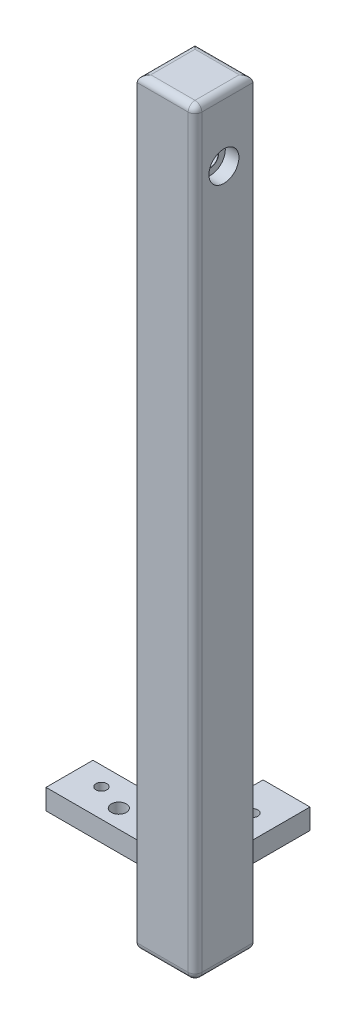
from build123d import *

# Parameters (mm, degrees)
SKETCH1_W                      = 8.5
SKETCH1_H                      = 111.5
BOSS_EXTRUDE5_DEPTH            = 8.5
M5X0_8_TAPPED_HOLE2_D          = 4.2
M5X0_8_TAPPED_HOLE2_DEPTH      = 20
M5X0_8_TAPPED_HOLE2_TIP        = 1.2618073
SKETCH35_W                     = 8.5
SKETCH35_H                     = 3
BOSS_EXTRUDE6_DEPTH            = 15
F_2_2_2_2_DIAMETER_HOLE1_D     = 2.2
F_2_2_2_2_DIAMETER_HOLE1_DEPTH = 13
M2X0_4_TAPPED_HOLE5_D          = 1.6
M2X0_4_TAPPED_HOLE5_DEPTH      = 3
SKETCH40_W                     = 8.5
SKETCH40_H                     = 3
BOSS_EXTRUDE7_DEPTH            = 10
M2X0_4_TAPPED_HOLE4_D          = 1.6
M2X0_4_TAPPED_HOLE4_DEPTH      = 3
FILLET1_R                      = 1
M2X0_4_TAPPED_HOLE3_D          = 2
M2X0_4_TAPPED_HOLE3_DEPTH      = 5.2
M2X0_4_TAPPED_HOLE3_TIP        = 0.600860619
SKETCH49_W                     = 1.6
SKETCH49_H                     = 10
SKETCH49_W_2                   = 15
SKETCH49_H_2                   = 1.6
CUT_EXTRUDE1_DEPTH             = 10


with BuildPart() as part:
    # Sketch1 → Boss-Extrude5 (new body)
    with BuildSketch(Plane.XY):
        with Locations((4.25, -55.75)):
            Rectangle(SKETCH1_W, SKETCH1_H)
    extrude(amount=BOSS_EXTRUDE5_DEPTH)

    # M5x0.8 Tapped Hole2
    with Locations(Plane(origin=(0, -111.5, 0), x_dir=(-1, 0, 0), z_dir=(0, -1, 0))):
        with Locations((-4.25, -4.25)):
            Hole(M5X0_8_TAPPED_HOLE2_D / 2, depth=M5X0_8_TAPPED_HOLE2_DEPTH)
            with Locations((0, 0, -(M5X0_8_TAPPED_HOLE2_DEPTH + M5X0_8_TAPPED_HOLE2_TIP / 2))):  # 118° drill point
                Cone(0, M5X0_8_TAPPED_HOLE2_D / 2, M5X0_8_TAPPED_HOLE2_TIP, mode=Mode.SUBTRACT)

    # Sketch35 → Boss-Extrude6 (add)
    with BuildSketch(Plane.ZY):
        with Locations((4.25, -100.5)):
            Rectangle(SKETCH35_W, SKETCH35_H)
    extrude(amount=BOSS_EXTRUDE6_DEPTH)

    # Ø2.2 (2.2) Diameter Hole1
    with Locations(Plane(origin=(0, -99, 0), x_dir=(1, 0, 0), z_dir=(0, 1, 0))):
        with Locations((-7, -4.2)):
            Hole(F_2_2_2_2_DIAMETER_HOLE1_D / 2, depth=F_2_2_2_2_DIAMETER_HOLE1_DEPTH)

    # M2x0.4 Tapped Hole5
    with Locations(Plane(origin=(0, -99, 0), x_dir=(1, 0, 0), z_dir=(0, 1, 0))):
        with Locations((-11, -2.75)):
            Hole(M2X0_4_TAPPED_HOLE5_D / 2, depth=M2X0_4_TAPPED_HOLE5_DEPTH)

    # Sketch40 → Boss-Extrude7 (add)
    with BuildSketch(Plane(origin=(0, 0, 0), x_dir=(-1, 0, 0), z_dir=(0, 0, -1))):
        with Locations((-4.25, -100.5)):
            Rectangle(SKETCH40_W, SKETCH40_H)
    extrude(amount=BOSS_EXTRUDE7_DEPTH)

    # M2x0.4 Tapped Hole4
    with Locations(Plane(origin=(0, -99, 0), x_dir=(1, 0, 0), z_dir=(0, 1, 0))):
        with Locations((3.45, 5)):
            Hole(M2X0_4_TAPPED_HOLE4_D / 2, depth=M2X0_4_TAPPED_HOLE4_DEPTH)

    # Sketch45 → CBORE for M2 Socket Head Cap Screw1 (revolve, cut)
    with BuildSketch(Plane(origin=(8.5, -9.5, 4.25), x_dir=(0, 0, -1), z_dir=(0, 1, 0))):
        Polygon((0, 0), (0, 23.500025), (1.2, 23.500025), (1.2, 2.025), (1.225, 2), (2.2, 2), (2.2, 0), align=None)
    revolve(axis=Axis((14.85, -9.5, 4.25), (-1, 0, 0)), mode=Mode.SUBTRACT)

    # Fillet1
    fillet1_edges = [part.edges().sort_by_distance(p)[0] for p in [
        (4.25, 0, 8.5),
        (2.15, -111.5, 4.25),
        (8.5, -55.75, 8.5),
        (4.25, 0, 0),
        (4.25, -111.5, 0),
        (4.25, -111.5, 8.5),
        (8.5, 0, 4.25),
        (0, 0, 4.25),
        (0, -111.5, 4.25),
        (8.5, -111.5, 4.25),
    ]]
    fillet(fillet1_edges, radius=FILLET1_R)

    # M2x0.4 Tapped Hole3
    with Locations(Plane(origin=(0, 0, 0), x_dir=(-1, 0, 0), z_dir=(0, 0, -1))):
        with Locations((-3.45, -26.8), (-3.45, -84.2), (-3.45, -31.1), (-3.45, -79.9)):
            Hole(M2X0_4_TAPPED_HOLE3_D / 2, depth=M2X0_4_TAPPED_HOLE3_DEPTH)
            with Locations((0, 0, -(M2X0_4_TAPPED_HOLE3_DEPTH + M2X0_4_TAPPED_HOLE3_TIP / 2))):  # 118° drill point
                Cone(0, M2X0_4_TAPPED_HOLE3_D / 2, M2X0_4_TAPPED_HOLE3_TIP, mode=Mode.SUBTRACT)

    # Sketch49 → Cut-Extrude1 (cut)
    with BuildSketch(Plane(origin=(0, -99, 0), x_dir=(1, 0, 0), z_dir=(0, 1, 0))):
        with Locations((7.7, 5)):
            Rectangle(SKETCH49_W, SKETCH49_H)
        with Locations((-7.5, -7.7)):
            Rectangle(SKETCH49_W_2, SKETCH49_H_2)
    extrude(amount=-CUT_EXTRUDE1_DEPTH, mode=Mode.SUBTRACT)


solid = part.part
